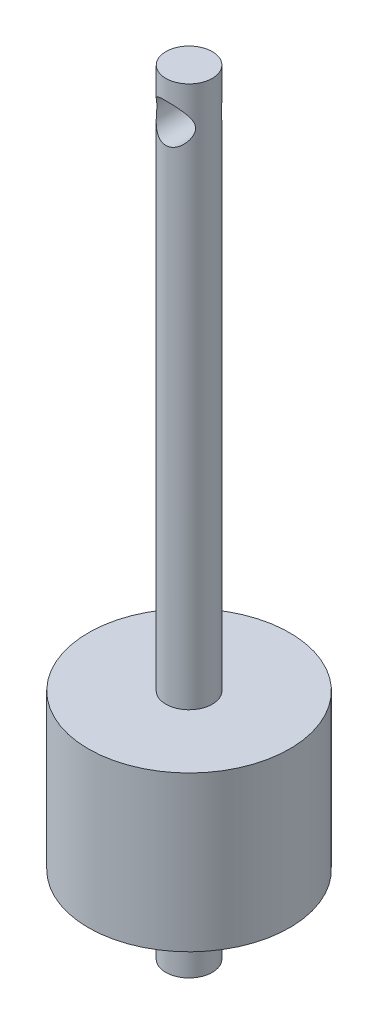
from build123d import *

# Parameters (mm, degrees)
ESQUISSE2_R                  = 2.5
ENL_V_MAT_EXTRU_1_DEPTH      = 14
ENL_V_MAT_EXTRU_1_DEPTH_BACK = 14


with BuildPart() as part:
    # Esquisse1 → Révolution1 (revolve)
    with BuildSketch(Plane.XY):
        Polygon((0, 0), (0, -100), (-3, -100), (-3, -90), (-13, -90), (-13, -70), (-3, -70), (-3, 0), align=None)
    revolve(axis=Axis((0, 0, 0), (0, -1, 0)))

    # Esquisse2 → Enlèv. mat.-Extru.1 (cut, two sides)
    with BuildSketch(Plane.XY) as enl_v_mat_extru_1_sk:
        with Locations((0, -5)):
            Circle(ESQUISSE2_R)
    extrude(amount=ENL_V_MAT_EXTRU_1_DEPTH, mode=Mode.SUBTRACT)
    extrude(enl_v_mat_extru_1_sk.sketch, amount=-ENL_V_MAT_EXTRU_1_DEPTH_BACK, mode=Mode.SUBTRACT)


solid = part.part
